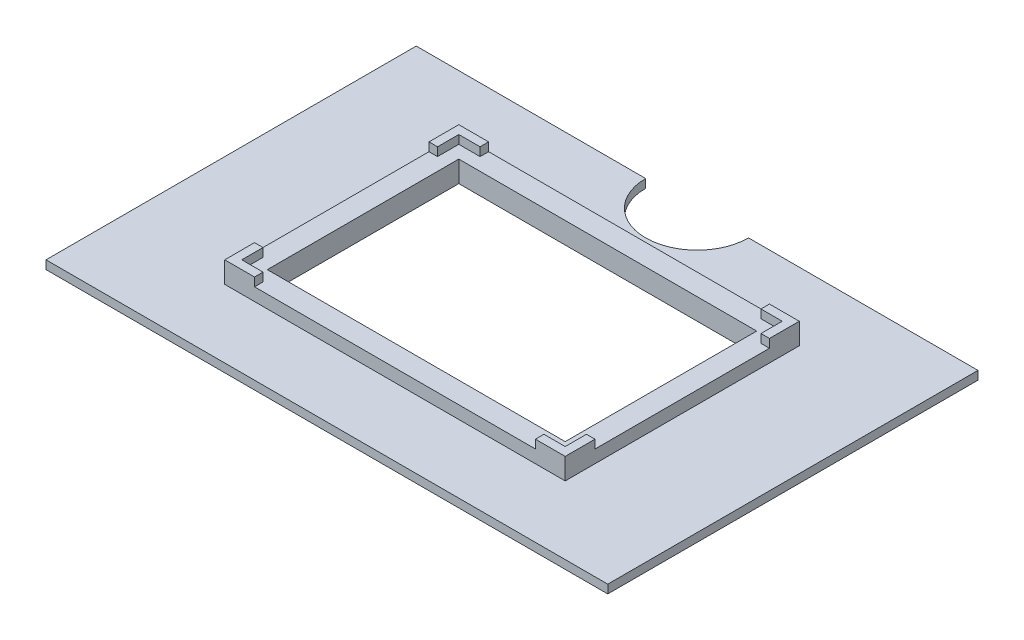
from build123d import *

# Parameters (mm, degrees)
SKETCH1_W           = 132
SKETCH1_H           = 87
BOSS_EXTRUDE1_DEPTH = 2
SKETCH2_W           = 80
SKETCH2_H           = 55
BOSS_EXTRUDE2_DEPTH = 5
SKETCH3_W           = 76
SKETCH3_H           = 51
CUT_EXTRUDE1_DEPTH  = 2
CUT_EXTRUDE2_REACH  = 7
SKETCH4_W           = 70
SKETCH4_H           = 45
SKETCH5_W           = 2
SKETCH5_H           = 41
SKETCH5_W_2         = 66
SKETCH5_H_2         = 2
CUT_EXTRUDE3_DEPTH  = 2
CUT_EXTRUDE4_DEPTH  = 2


with BuildPart() as part:
    # Sketch1 → Boss-Extrude1 (new body)
    with BuildSketch(Plane(origin=(0, 0, 0), x_dir=(1, 0, 0), z_dir=(0, 1, 0))):
        Rectangle(SKETCH1_W, SKETCH1_H)
    extrude(amount=BOSS_EXTRUDE1_DEPTH)

    # Sketch2 → Boss-Extrude2 (add)
    with BuildSketch(Plane(origin=(0, 2, 0), x_dir=(1, 0, 0), z_dir=(0, 1, 0))):
        Rectangle(SKETCH2_W, SKETCH2_H)
    extrude(amount=BOSS_EXTRUDE2_DEPTH)

    # Sketch3 → Cut-Extrude1 (cut)
    with BuildSketch(Plane(origin=(0, 7, 0), x_dir=(1, 0, 0), z_dir=(0, 1, 0))):
        Rectangle(SKETCH3_W, SKETCH3_H)
    extrude(amount=-CUT_EXTRUDE1_DEPTH, mode=Mode.SUBTRACT)

    # Sketch4 → Cut-Extrude2 (cut, up to next)
    with BuildSketch(Plane(origin=(0, 5, 0), x_dir=(1, 0, 0), z_dir=(0, 1, 0)), mode=Mode.PRIVATE) as cut_extrude2_sk1:
        Rectangle(SKETCH4_W, SKETCH4_H)
    cut_extrude2_tool1 = extrude(cut_extrude2_sk1.sketch, amount=-CUT_EXTRUDE2_REACH, mode=Mode.PRIVATE) & part.part
    add(cut_extrude2_tool1.solids().sort_by_distance((0, 5, 0))[0], mode=Mode.SUBTRACT)

    # Sketch5 → Cut-Extrude3 (cut)
    with BuildSketch(Plane(origin=(0, 7, 0), x_dir=(1, 0, 0), z_dir=(0, 1, 0))):
        with Locations((-39, 0)):
            Rectangle(SKETCH5_W, SKETCH5_H)
        with Locations((39, 0)):
            Rectangle(SKETCH5_W, SKETCH5_H)
        with Locations((0, 26.5)):
            Rectangle(SKETCH5_W_2, SKETCH5_H_2)
        with Locations((0, -26.5)):
            Rectangle(SKETCH5_W_2, SKETCH5_H_2)
    extrude(amount=-CUT_EXTRUDE3_DEPTH, mode=Mode.SUBTRACT)

    # Sketch6 → Cut-Extrude4 (cut)
    with BuildSketch(Plane(origin=(0, 2, 0), x_dir=(1, 0, 0), z_dir=(0, 1, 0))):
        with BuildLine():
            Line((-12.085608445, 43.5), (12.085608445, 43.5))
            ThreePointArc((12.085608445, 43.5), (0, 31.414391555), (-12.085608445, 43.5))
        make_face()
    extrude(amount=-CUT_EXTRUDE4_DEPTH, mode=Mode.SUBTRACT)


solid = part.part
